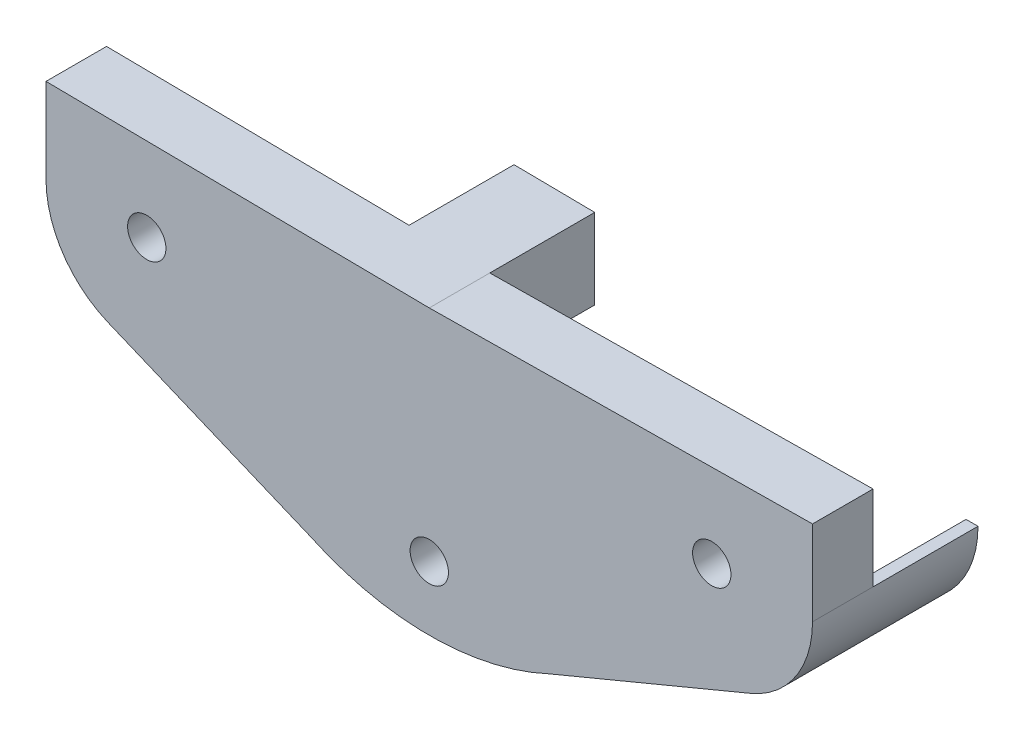
from build123d import *

# Parameters (mm, degrees)
SKETCH_1_R      = 0.95
EXTRUDE_1_DEPTH = 3
EXTRUDE_2_DEPTH = 5.2


with BuildPart() as part:
    # 草图1 → 凸台-拉伸1 (new body)
    with BuildSketch(Plane.XY):
        with BuildLine():
            Line((5.942462138, -8.684131796), (15.917990129, -4.533184225))
            ThreePointArc((15.917990129, -4.533184225), (18.153297697, -2.694164403), (18.992427879, 0.076116155))
            Line((18.992427879, 0.076116155), (18.992427879, 4.276025841))
            Line((18.992427879, 4.276025841), (0, 4.049500215))
            Line((0, 4.049500215), (-18.992427879, 4.276025841))
            Line((-18.992427879, 4.276025841), (-18.992427879, 0.076116155))
            ThreePointArc((-18.992427879, 0.076116155), (-18.153297697, -2.694164403), (-15.917990129, -4.533184225))
            Line((-15.917990129, -4.533184225), (-5.942462138, -8.684131796))
            ThreePointArc((-5.942462138, -8.684131796), (0, -10.002483291), (5.942462138, -8.684131796))
        make_face()
        with Locations((-14, 0.076116155)):
            Circle(SKETCH_1_R, mode=Mode.SUBTRACT)
        with Locations((14, 0.076116155)):
            Circle(SKETCH_1_R, mode=Mode.SUBTRACT)
        with Locations((0, -6.834517122)):
            Circle(SKETCH_1_R, mode=Mode.SUBTRACT)
    extrude(amount=EXTRUDE_1_DEPTH)

    # 草图2 → 凸台-拉伸2 (add)
    with BuildSketch(Plane(origin=(0, 0, 0), x_dir=(-1, 0, 0), z_dir=(0, 0, -1))):
        with BuildLine():
            ThreePointArc((-18.992427879, 0.076116155), (-18.153297697, -2.694164403), (-15.917990129, -4.533184225))
            Line((-15.917990129, -4.533184225), (-15.690391283, -3.98622028))
            ThreePointArc((-15.690391283, -3.98622028), (-17.66044544, -2.36542827), (-18.4, 0.076116155))
            Line((-18.4, 0.076116155), (-18.992427879, 0.076116155))
        make_face()
        Polygon((3.999715516, 4.097205441), (0, 4.049500215), (0, 0.076116155), (3.999715516, 0), align=None)
    extrude(amount=EXTRUDE_2_DEPTH)


solid = part.part
